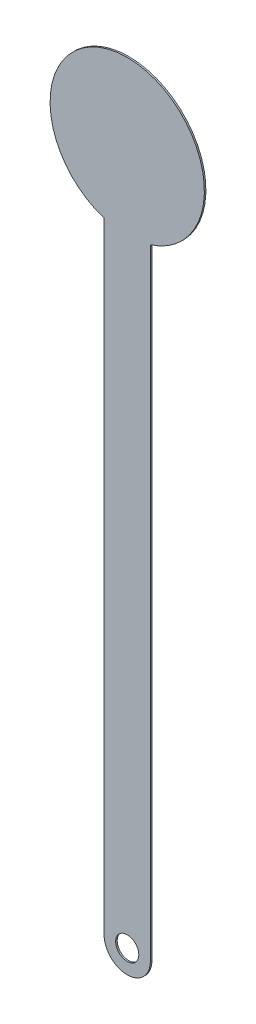
from build123d import *

# Parameters (mm, degrees)
SKETCH_1_R      = 0.75
EXTRUDE_1_DEPTH = 0.1


with BuildPart() as part:
    # 草图1 → 凸台-拉伸1 (new body)
    with BuildSketch(Plane.XY):
        with BuildLine():
            Line((1.5, -4.769696007), (1.5, -45))
            ThreePointArc((1.5, -45), (0, -46.5), (-1.5, -45))
            Line((-1.5, -45), (-1.5, -4.769696007))
            ThreePointArc((-1.5, -4.769696007), (0, 5), (1.5, -4.769696007))
        make_face()
        with Locations((0, -45)):
            Circle(SKETCH_1_R, mode=Mode.SUBTRACT)
    extrude(amount=EXTRUDE_1_DEPTH)


solid = part.part
